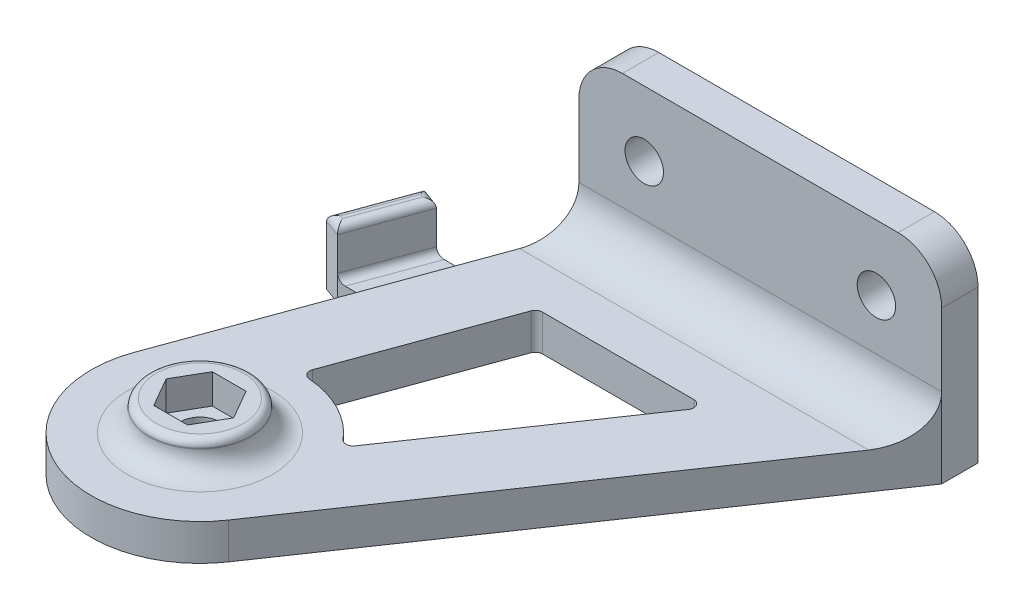
from build123d import *

# Parameters (mm, degrees)
SKETCH3_W            = 50
SKETCH3_H            = 27
BOSS_EXTRUDE1_DEPTH  = 5
BOSS_EXTRUDE2_DEPTH  = 5
M5_CLEARANCE_HOLE1_D = 5.3
FILLET1_R            = 6
M5_CLEARANCE_HOLE2_D = 5.3
SKETCH11_R           = 7
BOSS_EXTRUDE3_DEPTH  = 4.1
CUT_EXTRUDE1_DEPTH   = 23
FILLET2_R            = 3
FILLET3_R            = 1
SKETCH12_W           = 14
SKETCH12_H           = 4.5
BOSS_EXTRUDE4_DEPTH  = 2.5
BOSS_EXTRUDE5_DEPTH  = 2.5
SKETCH14_W           = 10.641777725
SKETCH14_H           = 9.1
BOSS_EXTRUDE6_DEPTH  = 2.5
FILLET4_R            = 1
CUT_EXTRUDE2_DEPTH   = 6
FILLET5_R            = 1


with BuildPart() as part:
    # Sketch3 → Boss-Extrude1 (new body)
    with BuildSketch(Plane.XY):
        with Locations((-63, -14.5)):
            Rectangle(SKETCH3_W, SKETCH3_H)
    extrude(amount=BOSS_EXTRUDE1_DEPTH)

    # Sketch5 → Boss-Extrude2 (add)
    with BuildSketch(Plane.XZ.offset(28)):
        with BuildLine():
            Line((-38, 5), (-77.841460566, 63.448623046))
            ThreePointArc((-77.841460566, 63.448623046), (-97.078370732, 68.348402277), (-104.331234438, 49.86969785))
            Line((-104.331234438, 49.86969785), (-88, 5))
            Line((-88, 5), (-88, 0))
            Line((-88, 0), (-38, 0))
            Line((-38, 0), (-38, 5))
        make_face()
    extrude(amount=-BOSS_EXTRUDE2_DEPTH)

    # M5 Clearance Hole1 (through all)
    with Locations(Plane.XY.offset(5)):
        with Locations((-79, -10), (-47, -10)):
            Hole(M5_CLEARANCE_HOLE1_D / 2)

    # Fillet1
    fillet1_edges = [part.edges().sort_by_distance(p)[0] for p in [
        (-63, -23, 5),
        (-88, -1, 2.5),
        (-38, -1, 2.5),
    ]]
    fillet(fillet1_edges, radius=FILLET1_R)

    # M5 Clearance Hole2 (through all)
    with Locations(Plane(origin=(0, -23, 0), x_dir=(1, 0, 0), z_dir=(0, 1, 0))):
        with Locations((-90.235845126, -55)):
            Hole(M5_CLEARANCE_HOLE2_D / 2)

    # Sketch11 → Boss-Extrude3 (add)
    with BuildSketch(Plane(origin=(0, -23, 0), x_dir=(1, 0, 0), z_dir=(0, 1, 0))):
        with Locations((-90.235845126, -55)):
            Circle(SKETCH11_R)
    extrude(amount=BOSS_EXTRUDE3_DEPTH)

    # Sketch10 → Cut-Extrude1 (cut, through all)
    with BuildSketch(Plane(origin=(0, -23, 0), x_dir=(1, 0, 0), z_dir=(0, 1, 0))):
        Polygon((-92.562566711, -50.97), (-94.889288296, -55), (-92.562566711, -59.03), (-87.909123541, -59.03), (-85.582401957, -55), (-87.909123541, -50.97), align=None)
    extrude(amount=CUT_EXTRUDE1_DEPTH, mode=Mode.SUBTRACT)

    # Fillet2
    fillet2_edges = [part.edges().sort_by_distance(p)[0] for p in [
        (-97.235845126, -23, 55),
    ]]
    fillet(fillet2_edges, radius=FILLET2_R)

    # Fillet3
    fillet3_edges = [part.edges().sort_by_distance(p)[0] for p in [
        (-97.235845126, -18.9, 55),
    ]]
    fillet(fillet3_edges, radius=FILLET3_R)

    # Sketch12 → Boss-Extrude4 (add)
    with BuildSketch(Plane(origin=(0, 0, 0), x_dir=(-1, 0, 0), z_dir=(0, 0, -1))):
        with Locations((63, -10)):
            Rectangle(SKETCH12_W, SKETCH12_H)
    extrude(amount=BOSS_EXTRUDE4_DEPTH)

    # Sketch13 → Boss-Extrude5 (add)
    with BuildSketch(Plane.XZ.offset(28)):
        Polygon((-91.639702343, 15), (-97.639702343, 15), (-101.279404685, 25), (-95.279404685, 25), align=None)
    extrude(amount=-BOSS_EXTRUDE5_DEPTH)

    # Sketch14 → Boss-Extrude6 (add)
    with BuildSketch(Plane(origin=(-81.397119802, 0, -29.626128763), x_dir=(-0.342020143, 0, 0.939692621), z_dir=(-0.939692621, 0, -0.342020143))):
        with Locations((52.811023164, -23.45)):
            Rectangle(SKETCH14_W, SKETCH14_H)
    extrude(amount=BOSS_EXTRUDE6_DEPTH)

    # Fillet4
    fillet4_edges = [part.edges().sort_by_distance(p)[0] for p in [
        (-93.459553514, -25.5, 20),
        (-99.459553514, -25.5, 20),
        (-99.459553514, -18.9, 20),
        (-102.454020461, -18.9, 24.572474821),
        (-98.814318119, -18.9, 14.572474821),
        (-101.808785066, -18.9, 19.144949642),
    ]]
    fillet(fillet4_edges, radius=FILLET4_R)

    # Sketch15 → Cut-Extrude2 (cut, through all)
    with BuildSketch(Plane(origin=(0, -23, 0), x_dir=(1, 0, 0), z_dir=(0, 1, 0))):
        with BuildLine():
            Line((-81.725865086, -17), (-58.2820459, -17))
            Line((-58.2820459, -17), (-78.739044792, -47.011033729))
            ThreePointArc((-78.739044792, -47.011033729), (-83.849487894, -42.541491209), (-90.461814506, -41.001823767))
            Line((-90.461814506, -41.001823767), (-81.725865086, -17))
        make_face()
    extrude(amount=-CUT_EXTRUDE2_DEPTH, mode=Mode.SUBTRACT)

    # Fillet5
    fillet5_edges = [part.edges().sort_by_distance(p)[0] for p in [
        (-90.461814506, -25.5, 41.001823767),
        (-81.725865086, -25.5, 17),
        (-58.2820459, -25.5, 17),
        (-78.739044792, -25.5, 47.011033729),
    ]]
    fillet(fillet5_edges, radius=FILLET5_R)


solid = part.part
